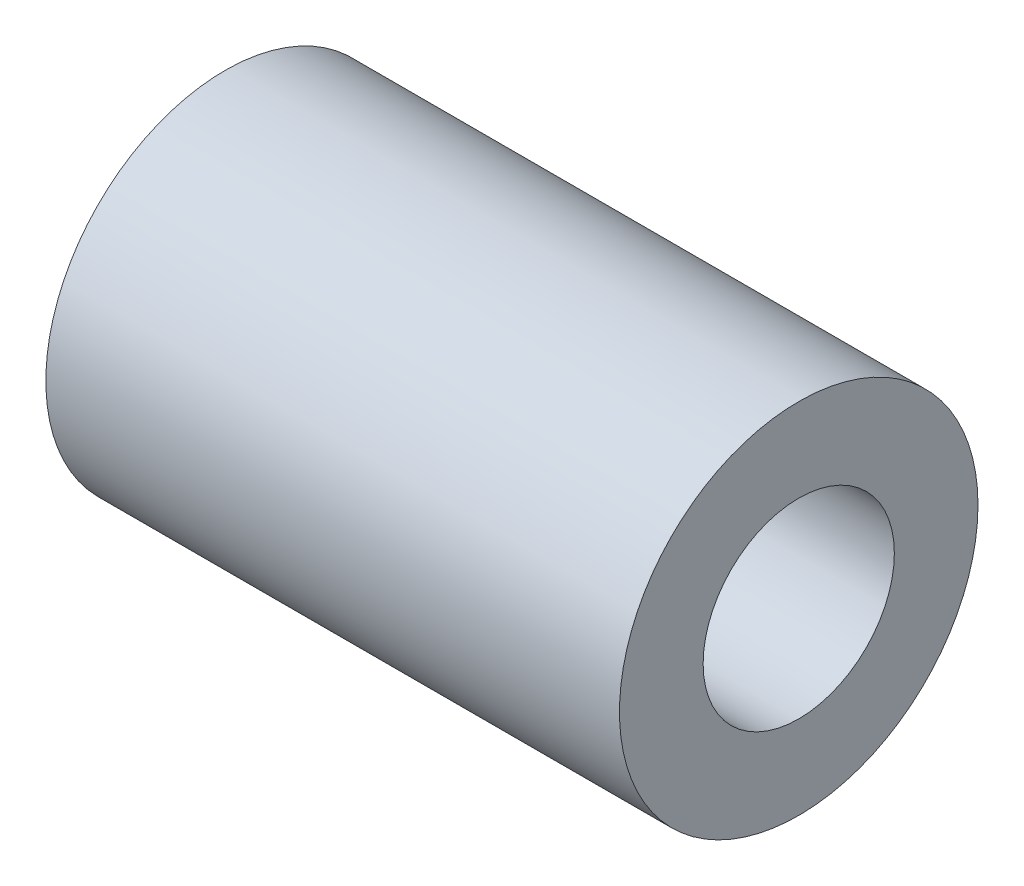
from build123d import *

# Parameters (mm, degrees)
SKETCH_1_R      = 7.5
SKETCH_1_R_2    = 4
EXTRUDE_1_DEPTH = 24


with BuildPart() as part:
    # 草图1 → 凸台-拉伸1 (new body)
    with BuildSketch(Plane(origin=(0, 0, 0), x_dir=(0, 0, -1), z_dir=(1, 0, 0))):
        Circle(SKETCH_1_R)
        Circle(SKETCH_1_R_2, mode=Mode.SUBTRACT)
    extrude(amount=EXTRUDE_1_DEPTH)


solid = part.part
